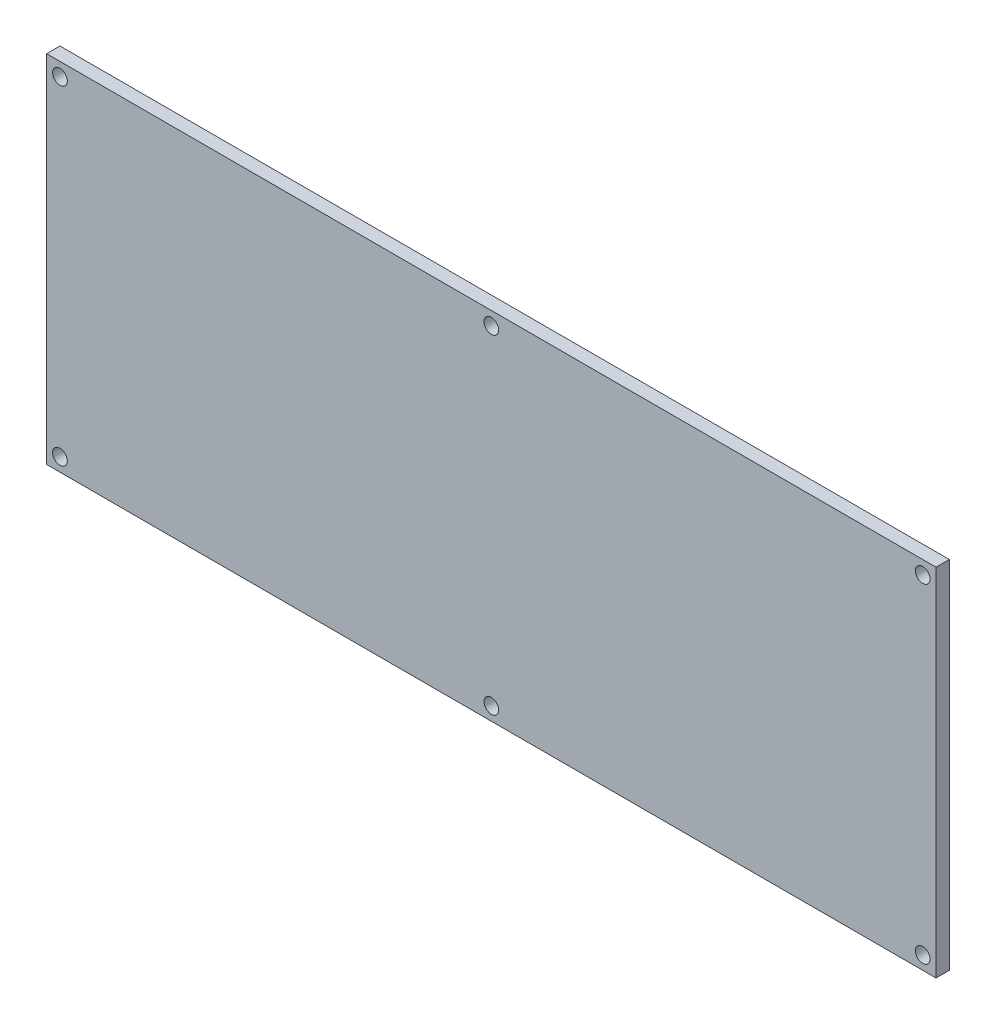
from build123d import *

# Parameters (mm, degrees)
SKETCH_1_W      = 200
SKETCH_1_H      = 80
SKETCH_1_R      = 1.65
EXTRUDE_1_DEPTH = 3


with BuildPart() as part:
    # 草图1 → 凸台-拉伸1 (new body)
    with BuildSketch(Plane.XY):
        Rectangle(SKETCH_1_W, SKETCH_1_H)
        with Locations((-97, 37)):
            Circle(SKETCH_1_R, mode=Mode.SUBTRACT)
        with Locations((0, 37)):
            Circle(SKETCH_1_R, mode=Mode.SUBTRACT)
        with Locations((97, 37)):
            Circle(SKETCH_1_R, mode=Mode.SUBTRACT)
        with Locations((-97, -37)):
            Circle(SKETCH_1_R, mode=Mode.SUBTRACT)
        with Locations((0, -37)):
            Circle(SKETCH_1_R, mode=Mode.SUBTRACT)
        with Locations((97, -37)):
            Circle(SKETCH_1_R, mode=Mode.SUBTRACT)
    extrude(amount=EXTRUDE_1_DEPTH)


solid = part.part
